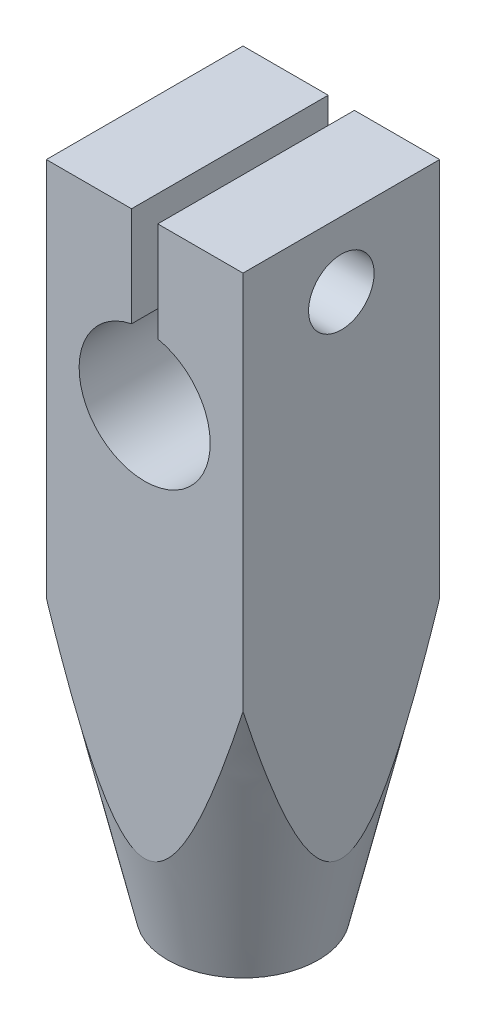
from build123d import *

# Parameters (mm, degrees)
SKETCH1_W           = 6
SKETCH1_H           = 20
SKETCH1_R           = 2
BOSS_EXTRUDE1_DEPTH = 3
SKETCH4_R           = 1.5
CUT_EXTRUDE1_DEPTH  = 10
SKETCH5_W           = 0.8
SKETCH5_H           = 4.49496607
CUT_EXTRUDE2_DEPTH  = 7
SKETCH6_R           = 1
CUT_EXTRUDE3_DEPTH  = 7


with BuildPart() as part:
    # Sketch1 → Boss-Extrude1 (new body, symmetric)
    with BuildSketch(Plane.XY):
        with Locations((0, 195)):
            Rectangle(SKETCH1_W, SKETCH1_H)
        with Locations((0, 200)):
            Circle(SKETCH1_R, mode=Mode.SUBTRACT)
    extrude(amount=BOSS_EXTRUDE1_DEPTH, both=True)

    # Sketch3 → Cut-Revolve3 (revolve, cut)
    with BuildSketch(Plane.XY):
        Polygon((-3, 185), (-2.3, 185), (-3, 188.032033112), (-6.917363823, 205), (-6.917363823, 185), align=None)
    revolve(axis=Axis((0, 200, 0), (0, -1, 0)), mode=Mode.SUBTRACT)

    # Sketch4 → Cut-Extrude1 (cut)
    with BuildSketch(Plane.XZ.offset(-185)):
        Circle(SKETCH4_R)
    extrude(amount=-CUT_EXTRUDE1_DEPTH, mode=Mode.SUBTRACT)

    # Sketch5 → Cut-Extrude2 (cut, through all)
    with BuildSketch(Plane.XY.offset(3)):
        with Locations((0, 202.752516965)):
            Rectangle(SKETCH5_W, SKETCH5_H)
    extrude(amount=-CUT_EXTRUDE2_DEPTH, mode=Mode.SUBTRACT)

    # Sketch6 → Cut-Extrude3 (cut, through all)
    with BuildSketch(Plane(origin=(3, 0, 0), x_dir=(0, 0, -1), z_dir=(1, 0, 0))):
        with Locations((0, 203)):
            Circle(SKETCH6_R)
    extrude(amount=-CUT_EXTRUDE3_DEPTH, mode=Mode.SUBTRACT)


solid = part.part
